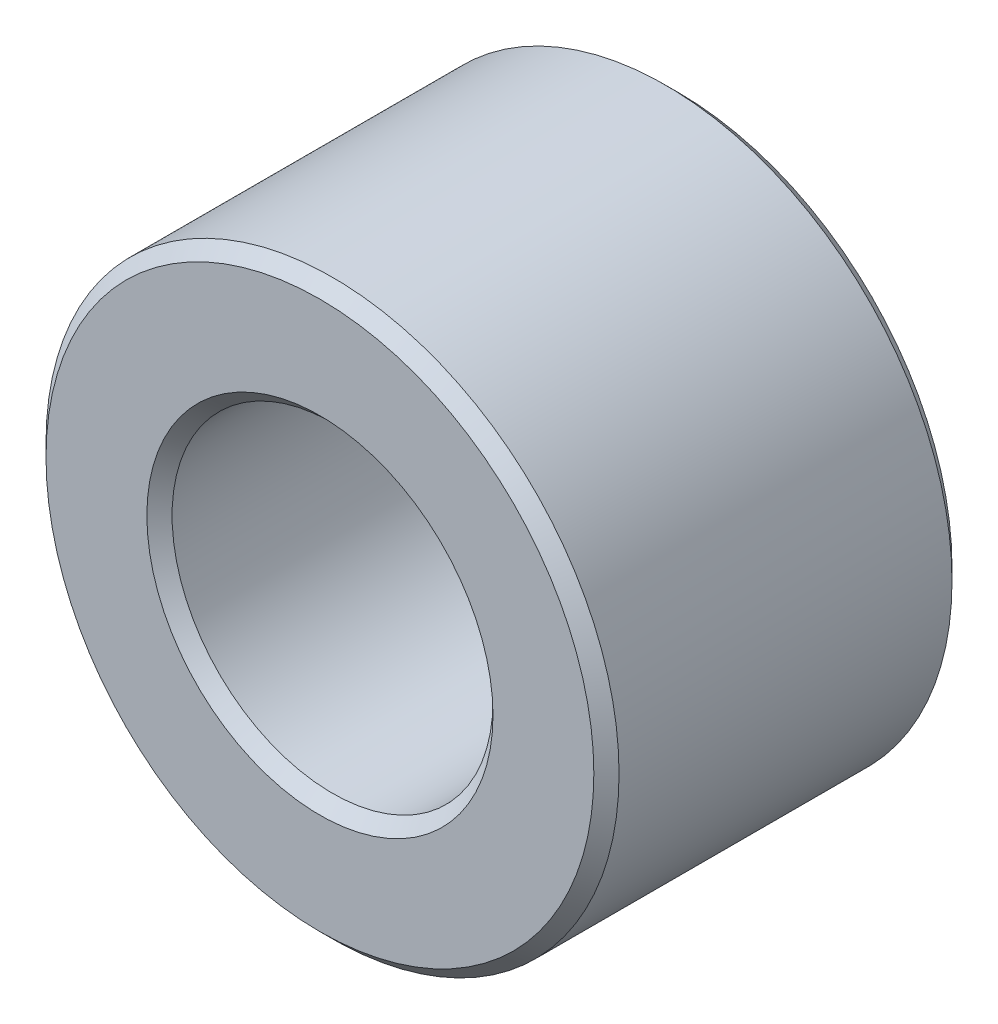
from build123d import *

# Parameters (mm, degrees)
SKETCH3_R                = 3.175
SKETCH3_R_2              = 1.778
BOSS_EXTRUDE1_DEPTH      = 1.984375
BOSS_EXTRUDE1_DEPTH_BACK = 1.984375
CHAMFER1_SIZE            = 0.1397


with BuildPart() as part:
    # Sketch3 → Boss-Extrude1 (new body, two sides)
    with BuildSketch(Plane.XY) as boss_extrude1_sk:
        Circle(SKETCH3_R)
        Circle(SKETCH3_R_2, mode=Mode.SUBTRACT)
    extrude(amount=BOSS_EXTRUDE1_DEPTH)
    extrude(boss_extrude1_sk.sketch, amount=-BOSS_EXTRUDE1_DEPTH_BACK)

    # Chamfer1
    chamfer1_edges = [part.edges().sort_by_distance(p)[0] for p in [
        (-3.175, 0, -1.984375),
        (-1.778, 0, -1.984375),
        (-3.175, 0, 1.984375),
        (-1.778, 0, 1.984375),
    ]]
    chamfer(chamfer1_edges, length=CHAMFER1_SIZE)


solid = part.part
